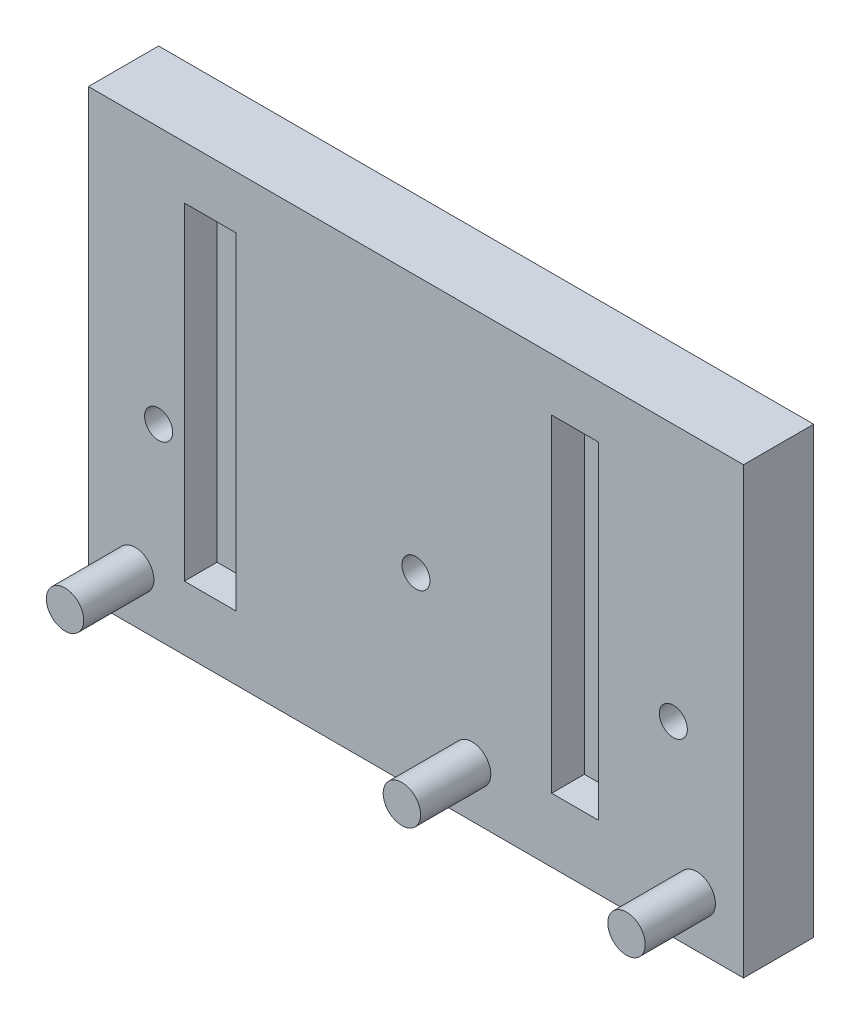
from build123d import *

# Parameters (mm, degrees)
SKETCH1_W                = 92
SKETCH1_H                = 77
SKETCH1_R                = 4
BOSS_EXTRUDE1_DEPTH      = 15
SKETCH1_3_R              = 4
BOSS_EXTRUDE2_DEPTH      = 15
BOSS_EXTRUDE2_DEPTH_BACK = 15
SKETCH2_R                = 3
CUT_EXTRUDE1_DEPTH       = 16
SKETCH2_3_W              = 11
SKETCH2_3_H              = 70
SKETCH2_3_W_2            = 10
CUT_EXTRUDE2_DEPTH       = 7


with BuildPart() as part:
    # Sketch1 → Boss-Extrude1 (new body)
    with BuildSketch(Plane.XY):
        with Locations((123.683888311, -870.843310138)):
            Rectangle(SKETCH1_W, SKETCH1_H)
        Polygon((169.683888311, -927.343310138), (217.683888311, -927.343310138), (217.683888311, -832.343310138), (169.683888311, -832.343310138), (169.683888311, -920.343310138), align=None)
        with Locations((207.683888311, -916.643310138)):
            Circle(SKETCH1_R, mode=Mode.SUBTRACT)
        Polygon((77.683888311, -909.343310138), (77.683888311, -920.343310138), (77.683888311, -927.343310138), (169.683888311, -927.343310138), (169.683888311, -920.343310138), (169.683888311, -909.343310138), align=None)
        with Locations((87.683888311, -916.643310138)):
            Circle(SKETCH1_R, mode=Mode.SUBTRACT)
        with Locations((159.683888311, -916.643310138)):
            Circle(SKETCH1_R, mode=Mode.SUBTRACT)
    extrude(amount=-BOSS_EXTRUDE1_DEPTH)

    # Sketch1_3 → Boss-Extrude2 (add, two sides)
    with BuildSketch(Plane.XY) as boss_extrude2_sk:
        with Locations((87.683888311, -916.643310138)):
            Circle(SKETCH1_3_R)
        with Locations((207.683888311, -916.643310138)):
            Circle(SKETCH1_3_R)
        with Locations((159.683888311, -916.643310138)):
            Circle(SKETCH1_3_R)
    extrude(amount=BOSS_EXTRUDE2_DEPTH)
    extrude(boss_extrude2_sk.sketch, amount=-BOSS_EXTRUDE2_DEPTH_BACK)

    # Sketch2 → Cut-Extrude1 (cut, through all)
    with BuildSketch(Plane.XY):
        with Locations((147.683888311, -887.343310138)):
            Circle(SKETCH2_R)
        with Locations((202.683888311, -887.343310138)):
            Circle(SKETCH2_R)
        with Locations((92.683888311, -887.343310138)):
            Circle(SKETCH2_R)
    extrude(amount=-CUT_EXTRUDE1_DEPTH, mode=Mode.SUBTRACT)

    # Sketch2_3 → Cut-Extrude2 (cut)
    with BuildSketch(Plane.XY):
        with Locations((103.683888311, -878.643310138)):
            Rectangle(SKETCH2_3_W, SKETCH2_3_H)
        with Locations((181.683888311, -878.643310138)):
            Rectangle(SKETCH2_3_W_2, SKETCH2_3_H)
    extrude(amount=-CUT_EXTRUDE2_DEPTH, mode=Mode.SUBTRACT)


solid = part.part
